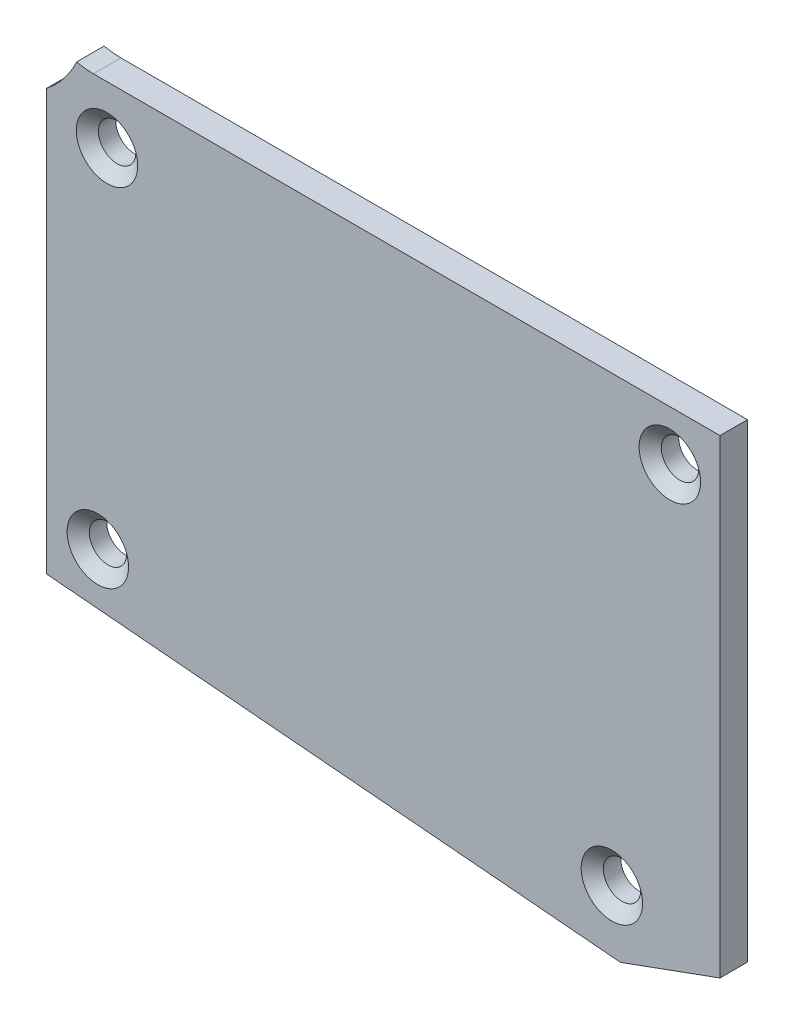
from build123d import *

# Parameters (mm, degrees)
BOSS_EXTRUDE1_DEPTH                               = 3.175
CSK_FOR_6_FLAT_HEAD_MACHINE_SCREW_100_D           = 4.3053
CSK_FOR_6_FLAT_HEAD_MACHINE_SCREW_100_DEPTH       = 3.175
CSK_FOR_6_FLAT_HEAD_MACHINE_SCREW_100_CSINK_D     = 7.0866
CSK_FOR_6_FLAT_HEAD_MACHINE_SCREW_100_CSINK_ANGLE = 100


with BuildPart() as part:
    # Sketch1 → Boss-Extrude1 (new body)
    with BuildSketch(Plane.XY):
        with BuildLine():
            Line((-129.2225, -27.397612764), (-129.2225, -75.892938058))
            Line((-129.2225, -75.892938058), (-63.036003441, -81.587899176))
            Line((-63.036003441, -81.587899176), (-51.562, -77.411703455))
            Line((-51.562, -77.411703455), (-51.562, -23.241))
            Line((-51.562, -23.241), (-123.825, -23.241))
            ThreePointArc((-123.825, -23.241), (-124.792433255, -23.184983239), (-125.746935831, -23.017681674))
            ThreePointArc((-125.746935831, -23.017681674), (-127.22324483, -25.415131417), (-129.2225, -27.397612764))
        make_face()
    extrude(amount=BOSS_EXTRUDE1_DEPTH)

    # CSK for #6 Flat Head Machine Screw (100)1
    with Locations(Plane.XY.offset(3.175)):
        with Locations((-123.300524074, -70.458632008), (-122.245302558, -29.869734201), (-57.342596045, -29.021596045), (-64.02512283, -74.422207293)):
            CounterSinkHole(CSK_FOR_6_FLAT_HEAD_MACHINE_SCREW_100_D / 2, CSK_FOR_6_FLAT_HEAD_MACHINE_SCREW_100_CSINK_D / 2, depth=CSK_FOR_6_FLAT_HEAD_MACHINE_SCREW_100_DEPTH, counter_sink_angle=CSK_FOR_6_FLAT_HEAD_MACHINE_SCREW_100_CSINK_ANGLE)


solid = part.part
